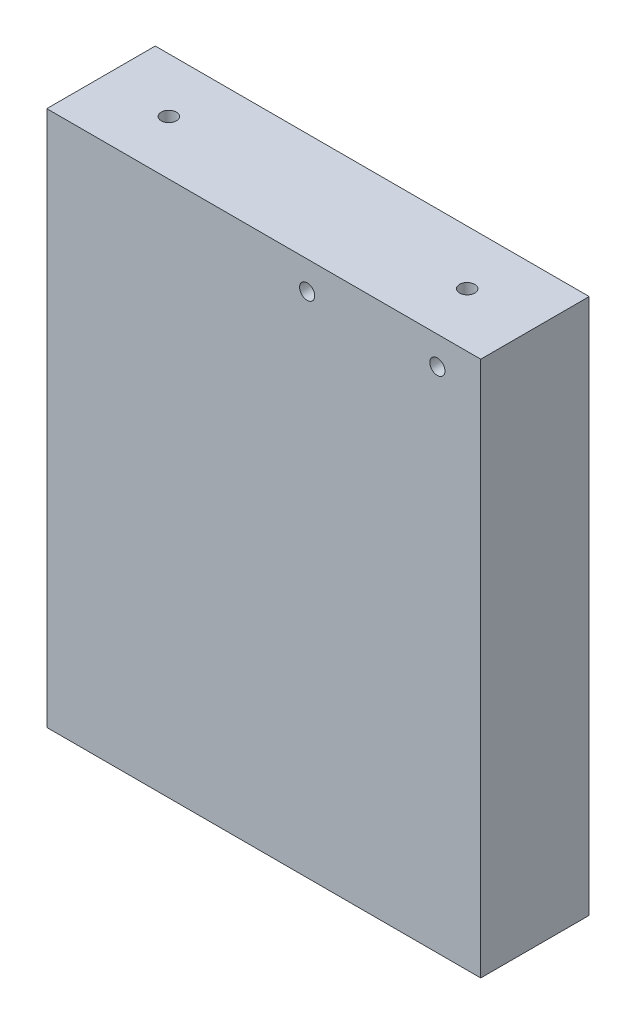
from build123d import *

# Parameters (mm, degrees)
SKETCH1_W                 = 50.8
SKETCH1_H                 = 12.7
BOSS_EXTRUDE1_DEPTH       = 62.738
F_8_32_TAPPED_HOLE1_D     = 3.4544
F_8_32_TAPPED_HOLE1_DEPTH = 17.6276
F_8_32_TAPPED_HOLE1_TIP   = 1.037806461
F_2_56_TAPPED_HOLE1_D     = 1.778
F_2_56_TAPPED_HOLE1_DEPTH = 12.7
F_2_56_TAPPED_HOLE1_TIP   = 0.53416509
F_2_56_TAPPED_HOLE2_D     = 1.778
F_2_56_TAPPED_HOLE2_DEPTH = 10.8204
F_2_56_TAPPED_HOLE2_TIP   = 0.53416509


with BuildPart() as part:
    # Sketch1 → Boss-Extrude1 (new body)
    with BuildSketch(Plane(origin=(0, 0, 0), x_dir=(1, 0, 0), z_dir=(0, 1, 0))):
        with Locations((25.4, -6.35)):
            Rectangle(SKETCH1_W, SKETCH1_H)
    extrude(amount=BOSS_EXTRUDE1_DEPTH)

    # #8-32 Tapped Hole1
    with Locations(Plane(origin=(0, 0, 0), x_dir=(-1, 0, 0), z_dir=(0, -1, 0))):
        with Locations((-6.35, -6.35), (-44.45, -6.35)):
            Hole(F_8_32_TAPPED_HOLE1_D / 2, depth=F_8_32_TAPPED_HOLE1_DEPTH)
            with Locations((0, 0, -(F_8_32_TAPPED_HOLE1_DEPTH + F_8_32_TAPPED_HOLE1_TIP / 2))):  # 118° drill point
                Cone(0, F_8_32_TAPPED_HOLE1_D / 2, F_8_32_TAPPED_HOLE1_TIP, mode=Mode.SUBTRACT)

    # #2-56 Tapped Hole1
    with Locations(Plane(origin=(0, 62.738, 0), x_dir=(1, 0, 0), z_dir=(0, 1, 0))):
        with Locations((7.9375, -6.35), (42.8625, -6.35)):
            Hole(F_2_56_TAPPED_HOLE1_D / 2, depth=F_2_56_TAPPED_HOLE1_DEPTH)
            with Locations((0, 0, -(F_2_56_TAPPED_HOLE1_DEPTH + F_2_56_TAPPED_HOLE1_TIP / 2))):  # 118° drill point
                Cone(0, F_2_56_TAPPED_HOLE1_D / 2, F_2_56_TAPPED_HOLE1_TIP, mode=Mode.SUBTRACT)

    # #2-56 Tapped Hole2
    with Locations(Plane.XY.offset(12.7)):
        with Locations((30.48, 59.436), (45.72, 59.436)):
            Hole(F_2_56_TAPPED_HOLE2_D / 2, depth=F_2_56_TAPPED_HOLE2_DEPTH)
            with Locations((0, 0, -(F_2_56_TAPPED_HOLE2_DEPTH + F_2_56_TAPPED_HOLE2_TIP / 2))):  # 118° drill point
                Cone(0, F_2_56_TAPPED_HOLE2_D / 2, F_2_56_TAPPED_HOLE2_TIP, mode=Mode.SUBTRACT)


solid = part.part
